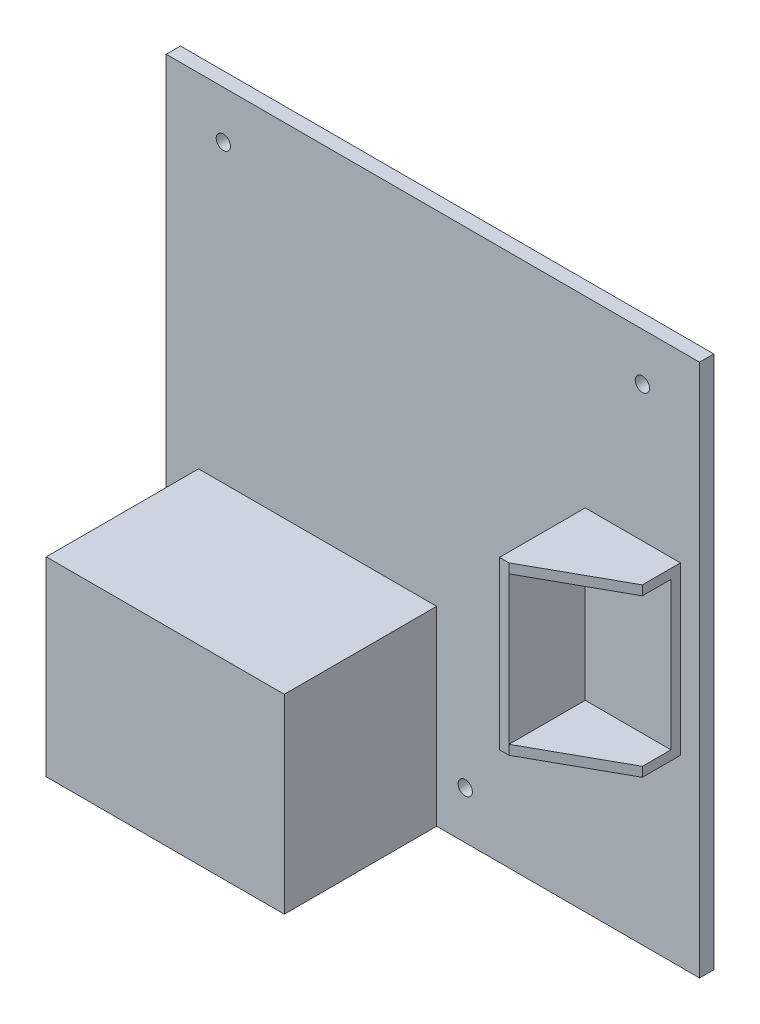
from build123d import *

# Parameters (mm, degrees)
SKETCH1_W           = 112
SKETCH1_H           = 112
BOSS_EXTRUDE1_DEPTH = 3
SKETCH2_W           = 50
SKETCH2_H           = 40
BOSS_EXTRUDE2_DEPTH = 32
CUT_EXTRUDE1_REACH  = 5
SKETCH3_R           = 1.5
SKETCH4_W           = 20
SKETCH4_H           = 35
BOSS_EXTRUDE3_DEPTH = 18
SKETCH5_W           = 18
SKETCH5_H           = 31
CUT_EXTRUDE2_DEPTH  = 16
CUT_EXTRUDE3_DEPTH  = 74.5


with BuildPart() as part:
    # Sketch1 → Boss-Extrude1 (new body)
    with BuildSketch(Plane.XY):
        Rectangle(SKETCH1_W, SKETCH1_H)
    extrude(amount=BOSS_EXTRUDE1_DEPTH)

    # Sketch2 → Boss-Extrude2 (add)
    with BuildSketch(Plane.XY.offset(3)):
        with Locations((-24.196765027, -36)):
            Rectangle(SKETCH2_W, SKETCH2_H)
    extrude(amount=BOSS_EXTRUDE2_DEPTH)

    # Sketch3 → Cut-Extrude1 (cut, up to next)
    with BuildSketch(Plane.XY.offset(3), mode=Mode.PRIVATE) as cut_extrude1_sk1:
        with Locations((-44, 46)):
            Circle(SKETCH3_R)
    cut_extrude1_tool1 = extrude(cut_extrude1_sk1.sketch, amount=-CUT_EXTRUDE1_REACH, mode=Mode.PRIVATE) & part.part
    add(cut_extrude1_tool1.solids().sort_by_distance((-44, 46, 3))[0], mode=Mode.SUBTRACT)
    # Sketch3 → Cut-Extrude1 (cut, up to next)
    with BuildSketch(Plane.XY.offset(3), mode=Mode.PRIVATE) as cut_extrude1_sk2:
        with Locations((44, 46)):
            Circle(SKETCH3_R)
    cut_extrude1_tool2 = extrude(cut_extrude1_sk2.sketch, amount=-CUT_EXTRUDE1_REACH, mode=Mode.PRIVATE) & part.part
    add(cut_extrude1_tool2.solids().sort_by_distance((44, 46, 3))[0], mode=Mode.SUBTRACT)
    # Sketch3 → Cut-Extrude1 (cut, up to next)
    with BuildSketch(Plane.XY.offset(3), mode=Mode.PRIVATE) as cut_extrude1_sk3:
        with Locations((6.803234973, -46)):
            Circle(SKETCH3_R)
    cut_extrude1_tool3 = extrude(cut_extrude1_sk3.sketch, amount=-CUT_EXTRUDE1_REACH, mode=Mode.PRIVATE) & part.part
    add(cut_extrude1_tool3.solids().sort_by_distance((6.803235, -46, 3))[0], mode=Mode.SUBTRACT)

    # Sketch4 → Boss-Extrude3 (add)
    with BuildSketch(Plane.XY.offset(3)):
        with Locations((42, 0)):
            Rectangle(SKETCH4_W, SKETCH4_H)
    extrude(amount=BOSS_EXTRUDE3_DEPTH)

    # Sketch5 → Cut-Extrude2 (cut)
    with BuildSketch(Plane.XY.offset(21)):
        with Locations((43, 0)):
            Rectangle(SKETCH5_W, SKETCH5_H)
    extrude(amount=-CUT_EXTRUDE2_DEPTH, mode=Mode.SUBTRACT)

    # Sketch6 → Cut-Extrude3 (cut, through all)
    with BuildSketch(Plane(origin=(0, 17.5, 0), x_dir=(1, 0, 0), z_dir=(0, 1, 0))):
        Polygon((34, -21), (52, -11), (52, -21), align=None)
    extrude(amount=-CUT_EXTRUDE3_DEPTH, mode=Mode.SUBTRACT)


solid = part.part
